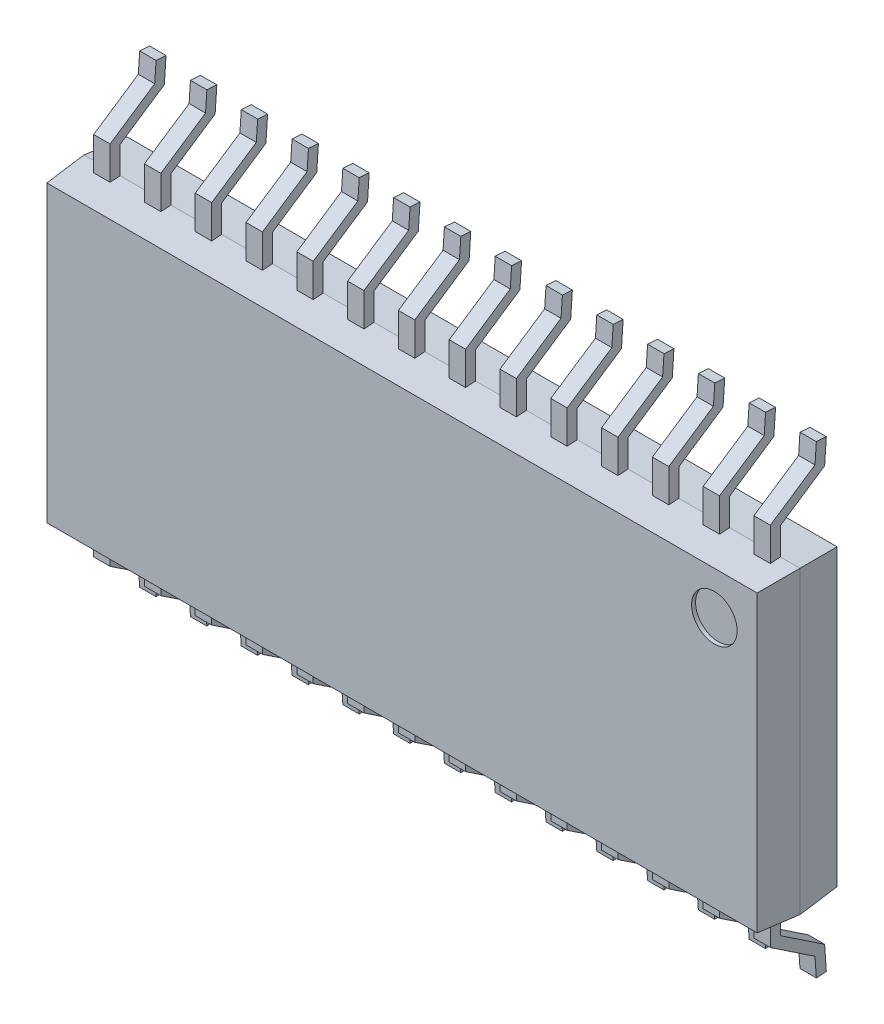
from build123d import *

# Parameters (mm, degrees)
SKETCH1_W             = 17.9
SKETCH1_H             = 7.5
BOSS_EXTRUDE1_DEPTH   = 1
BOSS_EXTRUDE1_TAPER   = 4
SKETCH2_W             = 17.9
SKETCH2_H             = 7.5
BOSS_EXTRUDE2_DEPTH   = 1
BOSS_EXTRUDE2_TAPER   = 4
EXTRUDE_THIN3_DEPTH   = 0.205
LPATTERN1_COUNT       = 14
LPATTERN1_PITCH       = 1.27
MIRROR3_COPY_1_DEPTH  = 0.205
MIRROR3_COPY_2_DEPTH  = 0.205
MIRROR3_COPY_3_DEPTH  = 0.205
MIRROR3_COPY_4_DEPTH  = 0.205
MIRROR3_COPY_5_DEPTH  = 0.205
MIRROR3_COPY_6_DEPTH  = 0.205
MIRROR3_COPY_7_DEPTH  = 0.205
MIRROR3_COPY_8_DEPTH  = 0.205
MIRROR3_COPY_9_DEPTH  = 0.205
MIRROR3_COPY_10_DEPTH = 0.205
MIRROR3_COPY_11_DEPTH = 0.205
MIRROR3_COPY_12_DEPTH = 0.205
MIRROR3_COPY_13_DEPTH = 0.205
SKETCH4_R             = 0.57
CUT_EXTRUDE1_DEPTH    = 0.1


with BuildPart() as part:
    # Sketch1 → Boss-Extrude1 (new body)
    with BuildSketch(Plane.XY):
        with Locations((8.95, 3.75)):
            Rectangle(SKETCH1_W, SKETCH1_H)
    extrude(amount=BOSS_EXTRUDE1_DEPTH, taper=BOSS_EXTRUDE1_TAPER)


with BuildPart() as body_2:
    # Sketch2 → Boss-Extrude2 (new body)
    with BuildSketch(Plane(origin=(0, 0, 0), x_dir=(-1, 0, 0), z_dir=(0, 0, -1))):
        with Locations((-8.95, 3.75)):
            Rectangle(SKETCH2_W, SKETCH2_H)
    extrude(amount=BOSS_EXTRUDE2_DEPTH, taper=BOSS_EXTRUDE2_TAPER)


with BuildPart() as body_3:
    # Sketch3 → Extrude-Thin3 (new body, symmetric)
    with BuildSketch(Plane(origin=(0.695, 0, 0), x_dir=(0, 0, -1), z_dir=(1, 0, 0))):
        Polygon((0, 0), (0, -0.7), (1.107372615, -1.4404), (1.15, -2.05), (0.900608987, -2.067439118), (0.866531154, -1.580103398), (-0.25, -0.83357991), (-0.25, 0), align=None)
    extrude_thin3 = extrude(amount=EXTRUDE_THIN3_DEPTH, both=True)


with BuildPart() as lpattern1_1:
    # LPattern1: Extrude-Thin3 ×14
    with Locations(*[(i * LPATTERN1_PITCH, 0, 0) for i in range(1, LPATTERN1_COUNT)]):
        add(extrude_thin3)


with BuildPart() as part_1:
    add(part.part)

    add(body_2.part)  # Mirror3 merges body 2
    # Mirror3: Extrude-Thin3 across plane
    add(extrude_thin3.mirror(Plane.ZX.offset(3.74)))

    # Mirror3 copy 1 sketch → Mirror3 copy 1 (add, symmetric)
    with BuildSketch(Plane(origin=(1.965, 7.48, 0), x_dir=(0, 0, -1), z_dir=(1, 0, 0))):
        Polygon((0, 0), (0, 0.7), (1.107372615, 1.4404), (1.15, 2.05), (0.900608987, 2.067439118), (0.866531154, 1.580103398), (-0.25, 0.83357991), (-0.25, 0), align=None)
    extrude(amount=MIRROR3_COPY_1_DEPTH, both=True)

    # Mirror3 copy 2 sketch → Mirror3 copy 2 (add, symmetric)
    with BuildSketch(Plane(origin=(3.235, 7.48, 0), x_dir=(0, 0, -1), z_dir=(1, 0, 0))):
        Polygon((0, 0), (0, 0.7), (1.107372615, 1.4404), (1.15, 2.05), (0.900608987, 2.067439118), (0.866531154, 1.580103398), (-0.25, 0.83357991), (-0.25, 0), align=None)
    extrude(amount=MIRROR3_COPY_2_DEPTH, both=True)

    # Mirror3 copy 3 sketch → Mirror3 copy 3 (add, symmetric)
    with BuildSketch(Plane(origin=(4.505, 7.48, 0), x_dir=(0, 0, -1), z_dir=(1, 0, 0))):
        Polygon((0, 0), (0, 0.7), (1.107372615, 1.4404), (1.15, 2.05), (0.900608987, 2.067439118), (0.866531154, 1.580103398), (-0.25, 0.83357991), (-0.25, 0), align=None)
    extrude(amount=MIRROR3_COPY_3_DEPTH, both=True)

    # Mirror3 copy 4 sketch → Mirror3 copy 4 (add, symmetric)
    with BuildSketch(Plane(origin=(5.775, 7.48, 0), x_dir=(0, 0, -1), z_dir=(1, 0, 0))):
        Polygon((0, 0), (0, 0.7), (1.107372615, 1.4404), (1.15, 2.05), (0.900608987, 2.067439118), (0.866531154, 1.580103398), (-0.25, 0.83357991), (-0.25, 0), align=None)
    extrude(amount=MIRROR3_COPY_4_DEPTH, both=True)

    # Mirror3 copy 5 sketch → Mirror3 copy 5 (add, symmetric)
    with BuildSketch(Plane(origin=(7.045, 7.48, 0), x_dir=(0, 0, -1), z_dir=(1, 0, 0))):
        Polygon((0, 0), (0, 0.7), (1.107372615, 1.4404), (1.15, 2.05), (0.900608987, 2.067439118), (0.866531154, 1.580103398), (-0.25, 0.83357991), (-0.25, 0), align=None)
    extrude(amount=MIRROR3_COPY_5_DEPTH, both=True)

    # Mirror3 copy 6 sketch → Mirror3 copy 6 (add, symmetric)
    with BuildSketch(Plane(origin=(8.315, 7.48, 0), x_dir=(0, 0, -1), z_dir=(1, 0, 0))):
        Polygon((0, 0), (0, 0.7), (1.107372615, 1.4404), (1.15, 2.05), (0.900608987, 2.067439118), (0.866531154, 1.580103398), (-0.25, 0.83357991), (-0.25, 0), align=None)
    extrude(amount=MIRROR3_COPY_6_DEPTH, both=True)

    # Mirror3 copy 7 sketch → Mirror3 copy 7 (add, symmetric)
    with BuildSketch(Plane(origin=(9.585, 7.48, 0), x_dir=(0, 0, -1), z_dir=(1, 0, 0))):
        Polygon((0, 0), (0, 0.7), (1.107372615, 1.4404), (1.15, 2.05), (0.900608987, 2.067439118), (0.866531154, 1.580103398), (-0.25, 0.83357991), (-0.25, 0), align=None)
    extrude(amount=MIRROR3_COPY_7_DEPTH, both=True)

    # Mirror3 copy 8 sketch → Mirror3 copy 8 (add, symmetric)
    with BuildSketch(Plane(origin=(10.855, 7.48, 0), x_dir=(0, 0, -1), z_dir=(1, 0, 0))):
        Polygon((0, 0), (0, 0.7), (1.107372615, 1.4404), (1.15, 2.05), (0.900608987, 2.067439118), (0.866531154, 1.580103398), (-0.25, 0.83357991), (-0.25, 0), align=None)
    extrude(amount=MIRROR3_COPY_8_DEPTH, both=True)

    # Mirror3 copy 9 sketch → Mirror3 copy 9 (add, symmetric)
    with BuildSketch(Plane(origin=(12.125, 7.48, 0), x_dir=(0, 0, -1), z_dir=(1, 0, 0))):
        Polygon((0, 0), (0, 0.7), (1.107372615, 1.4404), (1.15, 2.05), (0.900608987, 2.067439118), (0.866531154, 1.580103398), (-0.25, 0.83357991), (-0.25, 0), align=None)
    extrude(amount=MIRROR3_COPY_9_DEPTH, both=True)

    # Mirror3 copy 10 sketch → Mirror3 copy 10 (add, symmetric)
    with BuildSketch(Plane(origin=(13.395, 7.48, 0), x_dir=(0, 0, -1), z_dir=(1, 0, 0))):
        Polygon((0, 0), (0, 0.7), (1.107372615, 1.4404), (1.15, 2.05), (0.900608987, 2.067439118), (0.866531154, 1.580103398), (-0.25, 0.83357991), (-0.25, 0), align=None)
    extrude(amount=MIRROR3_COPY_10_DEPTH, both=True)

    # Mirror3 copy 11 sketch → Mirror3 copy 11 (add, symmetric)
    with BuildSketch(Plane(origin=(14.665, 7.48, 0), x_dir=(0, 0, -1), z_dir=(1, 0, 0))):
        Polygon((0, 0), (0, 0.7), (1.107372615, 1.4404), (1.15, 2.05), (0.900608987, 2.067439118), (0.866531154, 1.580103398), (-0.25, 0.83357991), (-0.25, 0), align=None)
    extrude(amount=MIRROR3_COPY_11_DEPTH, both=True)

    # Mirror3 copy 12 sketch → Mirror3 copy 12 (add, symmetric)
    with BuildSketch(Plane(origin=(15.935, 7.48, 0), x_dir=(0, 0, -1), z_dir=(1, 0, 0))):
        Polygon((0, 0), (0, 0.7), (1.107372615, 1.4404), (1.15, 2.05), (0.900608987, 2.067439118), (0.866531154, 1.580103398), (-0.25, 0.83357991), (-0.25, 0), align=None)
    extrude(amount=MIRROR3_COPY_12_DEPTH, both=True)

    # Mirror3 copy 13 sketch → Mirror3 copy 13 (add, symmetric)
    with BuildSketch(Plane(origin=(17.205, 7.48, 0), x_dir=(0, 0, -1), z_dir=(1, 0, 0))):
        Polygon((0, 0), (0, 0.7), (1.107372615, 1.4404), (1.15, 2.05), (0.900608987, 2.067439118), (0.866531154, 1.580103398), (-0.25, 0.83357991), (-0.25, 0), align=None)
    extrude(amount=MIRROR3_COPY_13_DEPTH, both=True)

    # Sketch4 → Cut-Extrude1 (cut)
    with BuildSketch(Plane.XY.offset(1)):
        with Locations((16.76, 6.36)):
            Circle(SKETCH4_R)
    extrude(amount=-CUT_EXTRUDE1_DEPTH, mode=Mode.SUBTRACT)


solid = Compound([body_3.part, lpattern1_1.part, part_1.part])
